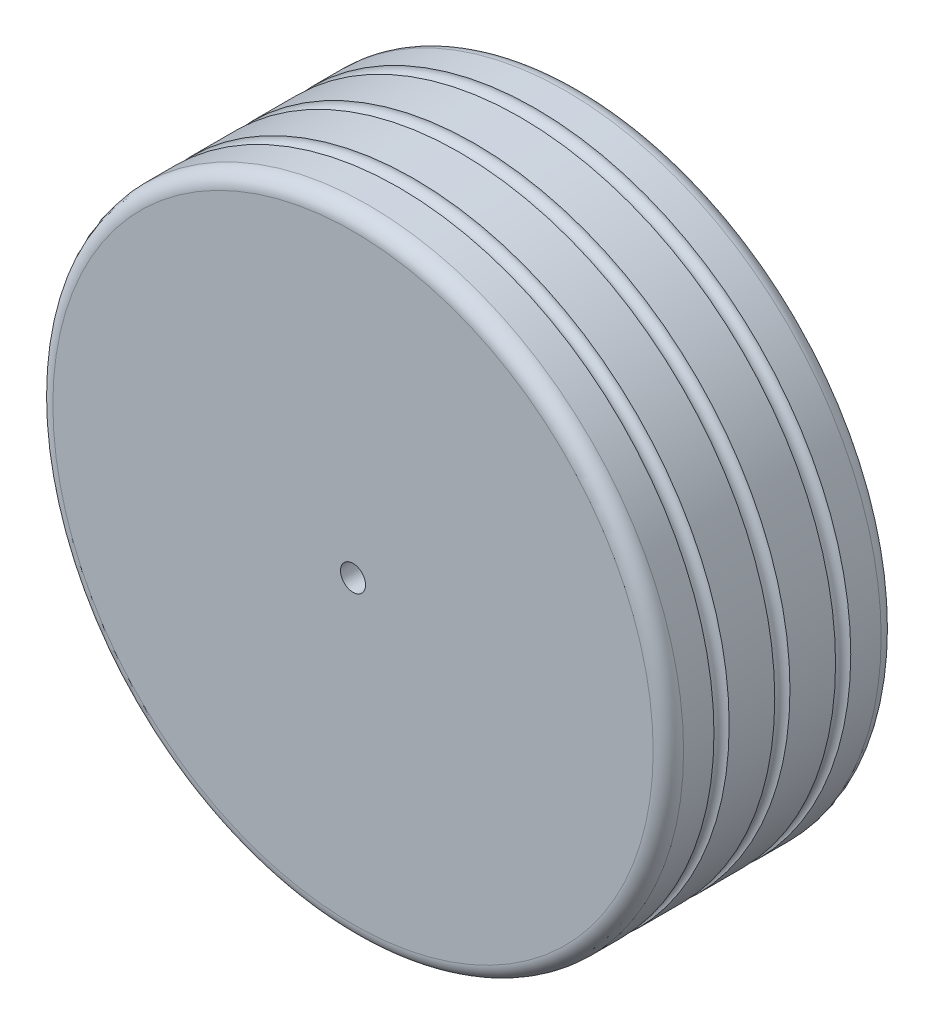
from build123d import *

# Parameters (mm, degrees)
SKICA1_R                 = 41.5
P_IDAT_VYSUNUT_M1_DEPTH  = 30
ZAOBLIT1_R               = 2
SKICA2_R                 = 1.65
ODEBRAT_VYSUNUT_M1_DEPTH = 7
SKICA3_R                 = 25
ODEBRAT_VYSUNUT_M2_DEPTH = 10
ZAOBLIT2_R               = 3
SKICA4_R                 = 1


with BuildPart() as part:
    # Skica1 → Přidat vysunutím1 (new body)
    with BuildSketch(Plane.XY):
        Circle(SKICA1_R)
    extrude(amount=P_IDAT_VYSUNUT_M1_DEPTH)

    # Zaoblit1
    zaoblit1_edges = [part.edges().sort_by_distance(p)[0] for p in [
        (-41.5, 0, 0),
        (-41.5, 0, 30),
    ]]
    fillet(zaoblit1_edges, radius=ZAOBLIT1_R)

    # Skica2 → Odebrat vysunutím1 (cut)
    with BuildSketch(Plane.XY.offset(30)):
        Circle(SKICA2_R)
    extrude(amount=-ODEBRAT_VYSUNUT_M1_DEPTH, mode=Mode.SUBTRACT)

    # Skica3 → Odebrat vysunutím2 (cut)
    with BuildSketch(Plane(origin=(0, 0, 0), x_dir=(-1, 0, 0), z_dir=(0, 0, -1))):
        Circle(SKICA3_R)
    extrude(amount=-ODEBRAT_VYSUNUT_M2_DEPTH, mode=Mode.SUBTRACT)

    # Zaoblit2
    zaoblit2_edges = [part.edges().sort_by_distance(p)[0] for p in [
        (25, 0, 10),
        (25, 0, 0),
    ]]
    fillet(zaoblit2_edges, radius=ZAOBLIT2_R)

    # Skica4 → Odebrat rotací1 (revolve, cut)
    with BuildSketch(Plane(origin=(0, 0, 0), x_dir=(0, 0, -1), z_dir=(1, 0, 0))):
        with Locations((-7, 41.5)):
            Circle(SKICA4_R)
        with Locations((-15, 41.5)):
            Circle(SKICA4_R)
        with Locations((-23, 41.5)):
            Circle(SKICA4_R)
    revolve(axis=Axis((0, 0, 23), (0, 0, 1)), mode=Mode.SUBTRACT)


solid = part.part
